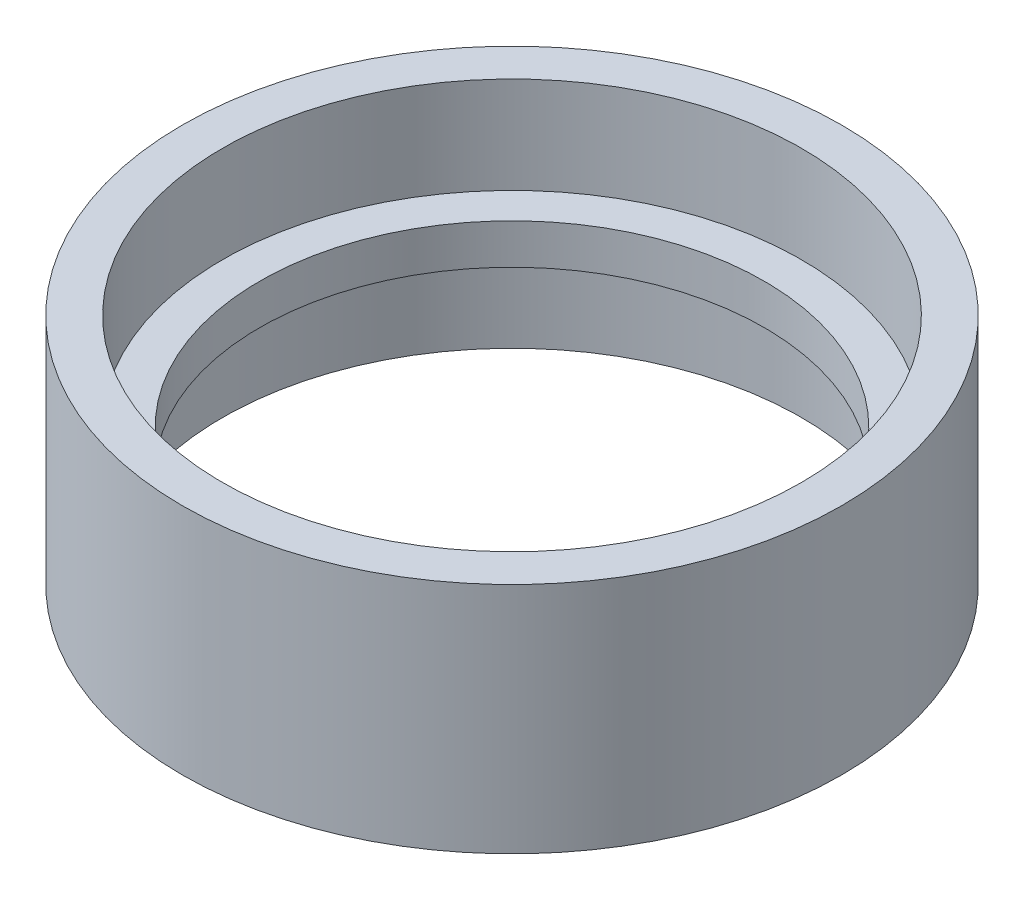
from build123d import *


with BuildPart() as part:
    # Эскиз1 → Повернуть1 (revolve)
    with BuildSketch(Plane.XY):
        Polygon((-36, 15), (-36, 3), (-41, 3), (-41, 32), (-36, 32), (-36, 20), (-31.374, 20), (-31.374, 15), align=None)
    revolve(axis=Axis((0, -1000, 0), (0, 1, 0)))


solid = part.part
